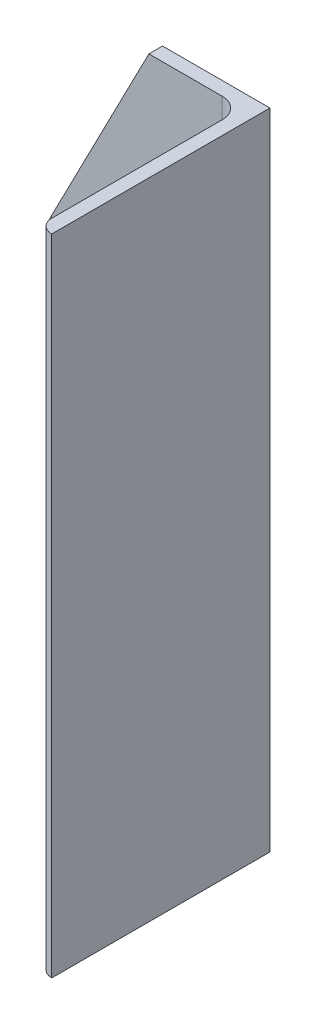
from build123d import *

# Parameters (mm, degrees)
HIERRO_ANGULAR_2_X_2_X_0_125_1_DEPTH = 150
CORTAR_EXTRUIR1_DEPTH                = 10
CORTAR_EXTRUIR2_REACH                = 168.317
CROQUIS4_R                           = 2.5


with BuildPart() as part:
    # Sketch1 → Hierro angular 2 X 2 X 0.125(1) (new body)
    with BuildSketch(Plane(origin=(0, 0, 0), x_dir=(-1, 0, 0), z_dir=(0, 1, 0))):
        with BuildLine():
            Line((0, 0), (0, 50.8))
            Line((0, 50.8), (0.00508, 50.8))
            ThreePointArc((0.00508, 50.8), (2.246551928, 49.871551928), (3.175, 47.63008))
            Line((3.175, 47.63008), (3.175, 7.9375))
            ThreePointArc((3.175, 7.9375), (4.569903955, 4.569903955), (7.9375, 3.175))
            Line((7.9375, 3.175), (47.63008, 3.175))
            ThreePointArc((47.63008, 3.175), (49.871551928, 2.246551928), (50.8, 0.00508))
            Line((50.8, 0.00508), (50.8, 0))
            Line((50.8, 0), (0, 0))
        make_face()
    extrude(amount=HIERRO_ANGULAR_2_X_2_X_0_125_1_DEPTH)

    # Croquis3 → Cortar-Extruir1 (cut)
    with BuildSketch(Plane(origin=(0, 0, 0), x_dir=(-1, 0, 0), z_dir=(0, 0, -1))):
        Polygon((50.8, 100), (25, 150), (50.8, 150), align=None)
    extrude(amount=-CORTAR_EXTRUIR1_DEPTH, mode=Mode.SUBTRACT)

    # Cortar-Extruir2: up to this face of the body (flat: up to its plane)
    cortar_extruir2_end = Plane(part.part.faces().sort_by_distance((-26.665136317, 69.509801857, 3.175))[0])
    # Croquis4 → Cortar-Extruir2 (cut, up to the picked face)
    with BuildSketch(Plane(origin=(0, 0, 0), x_dir=(-1, 0, 0), z_dir=(0, 0, -1)), mode=Mode.PRIVATE) as cortar_extruir2_sk1:
        with Locations((45.4, 9.88)):
            Circle(CROQUIS4_R)
    cortar_extruir2_tool1 = split(extrude(cortar_extruir2_sk1.sketch, amount=-CORTAR_EXTRUIR2_REACH, mode=Mode.PRIVATE), bisect_by=cortar_extruir2_end, keep=Keep.BOTH, mode=Mode.PRIVATE)
    # Croquis4 → Cortar-Extruir2 (cut, up to the picked face)
    with BuildSketch(Plane(origin=(0, 0, 0), x_dir=(-1, 0, 0), z_dir=(0, 0, -1)), mode=Mode.PRIVATE) as cortar_extruir2_sk2:
        with Locations((17.9, 9.88)):
            Circle(CROQUIS4_R)
    cortar_extruir2_tool2 = split(extrude(cortar_extruir2_sk2.sketch, amount=-CORTAR_EXTRUIR2_REACH, mode=Mode.PRIVATE), bisect_by=cortar_extruir2_end, keep=Keep.BOTH, mode=Mode.PRIVATE)
    # Croquis4 → Cortar-Extruir2 (cut, up to the picked face)
    with BuildSketch(Plane(origin=(0, 0, 0), x_dir=(-1, 0, 0), z_dir=(0, 0, -1)), mode=Mode.PRIVATE) as cortar_extruir2_sk3:
        with Locations((45.4, 90.13)):
            Circle(CROQUIS4_R)
    cortar_extruir2_tool3 = split(extrude(cortar_extruir2_sk3.sketch, amount=-CORTAR_EXTRUIR2_REACH, mode=Mode.PRIVATE), bisect_by=cortar_extruir2_end, keep=Keep.BOTH, mode=Mode.PRIVATE)
    # Croquis4 → Cortar-Extruir2 (cut, up to the picked face)
    with BuildSketch(Plane(origin=(0, 0, 0), x_dir=(-1, 0, 0), z_dir=(0, 0, -1)), mode=Mode.PRIVATE) as cortar_extruir2_sk4:
        with Locations((17.9, 90.13)):
            Circle(CROQUIS4_R)
    cortar_extruir2_tool4 = split(extrude(cortar_extruir2_sk4.sketch, amount=-CORTAR_EXTRUIR2_REACH, mode=Mode.PRIVATE), bisect_by=cortar_extruir2_end, keep=Keep.BOTH, mode=Mode.PRIVATE)
    add(cortar_extruir2_tool1.solids().sort_by(Axis((-45.4, 9.88, 0), (0, 0, 1)))[0], mode=Mode.SUBTRACT)
    add(cortar_extruir2_tool2.solids().sort_by(Axis((-17.9, 9.88, 0), (0, 0, 1)))[0], mode=Mode.SUBTRACT)
    add(cortar_extruir2_tool3.solids().sort_by(Axis((-45.4, 90.13, 0), (0, 0, 1)))[0], mode=Mode.SUBTRACT)
    add(cortar_extruir2_tool4.solids().sort_by(Axis((-17.9, 90.13, 0), (0, 0, 1)))[0], mode=Mode.SUBTRACT)


solid = part.part
